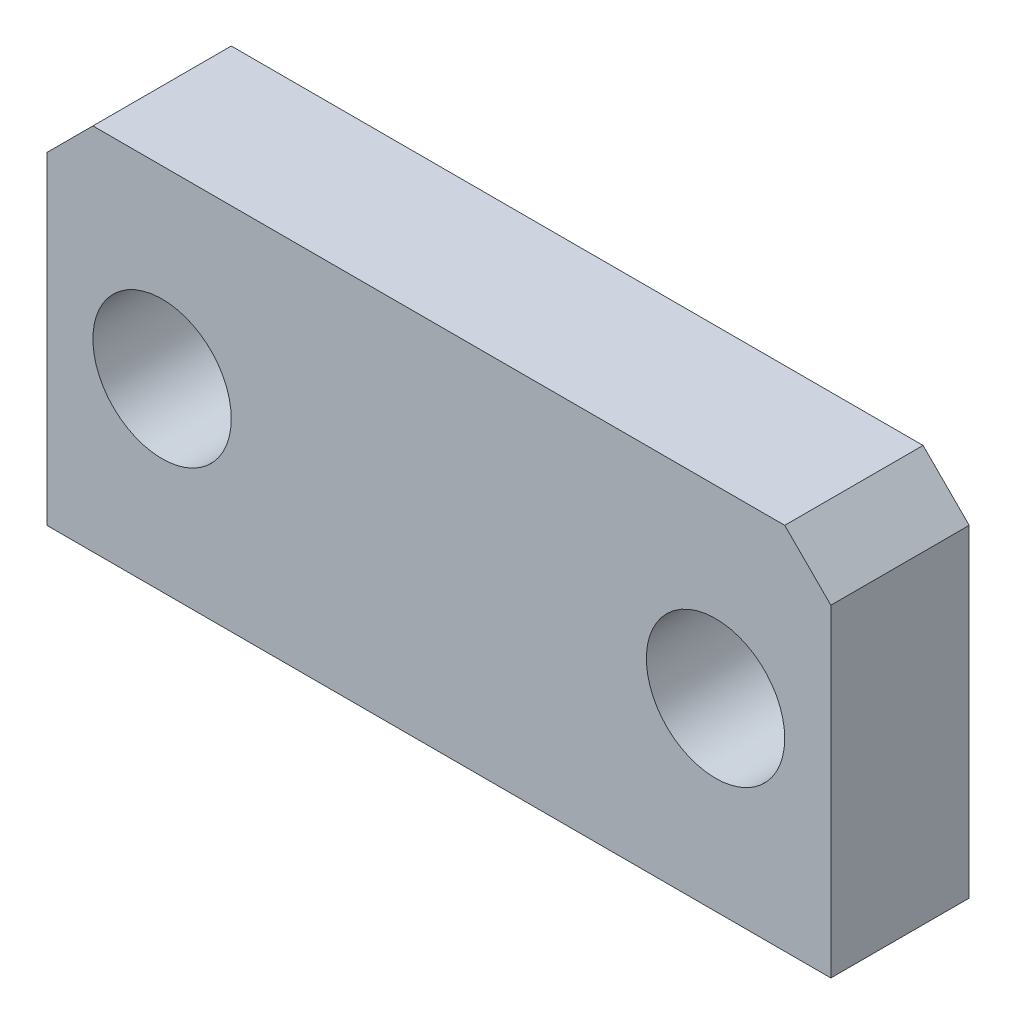
from build123d import *

# Parameters (mm, degrees)
ESQUISSE1_W        = 17
ESQUISSE1_H        = 8
ESQUISSE1_R        = 1.5
BOSS_EXTRU_1_DEPTH = 3
CHANFREIN1_SIZE    = 1


with BuildPart() as part:
    # Esquisse1 → Boss.-Extru.1 (new body)
    with BuildSketch(Plane.XY):
        Rectangle(ESQUISSE1_W, ESQUISSE1_H)
        with Locations((-6, 0)):
            Circle(ESQUISSE1_R, mode=Mode.SUBTRACT)
        with Locations((6, 0)):
            Circle(ESQUISSE1_R, mode=Mode.SUBTRACT)
    extrude(amount=BOSS_EXTRU_1_DEPTH)

    # Chanfrein1
    chanfrein1_edges = [part.edges().sort_by_distance(p)[0] for p in [
        (-8.5, 4, 1.5),
        (8.5, 4, 1.5),
    ]]
    chamfer(chanfrein1_edges, length=CHANFREIN1_SIZE)


solid = part.part
